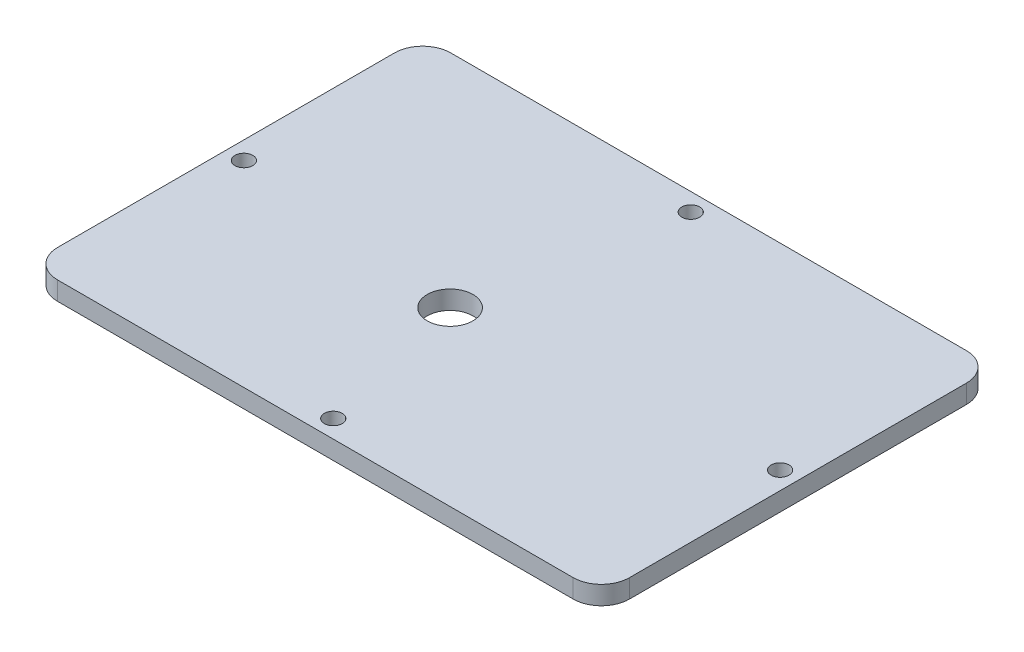
from build123d import *

# Parameters (mm, degrees)
SKETCH1_W           = 101.6
SKETCH1_H           = 69.85
BOSS_EXTRUDE1_DEPTH = 3.302
SKETCH4_R           = 1.5875
CUT_EXTRUDE1_DEPTH  = 4.302
FILLET1_R           = 5
SKETCH5_R           = 4.064
CUT_EXTRUDE2_DEPTH  = 4.302


with BuildPart() as part:
    # Sketch1 → Boss-Extrude1 (new body)
    with BuildSketch(Plane(origin=(0, 0, 0), x_dir=(1, 0, 0), z_dir=(0, 1, 0))):
        Rectangle(SKETCH1_W, SKETCH1_H)
    extrude(amount=BOSS_EXTRUDE1_DEPTH)

    # Sketch4 → Cut-Extrude1 (cut, through all)
    with BuildSketch(Plane(origin=(0, 0, 0), x_dir=(-1, 0, 0), z_dir=(0, -1, 0))):
        with Locations((0, 31.75)):
            Circle(SKETCH4_R)
        with Locations((-47.625, 0)):
            Circle(SKETCH4_R)
        with Locations((0, -31.75)):
            Circle(SKETCH4_R)
        with Locations((47.625, 0)):
            Circle(SKETCH4_R)
    extrude(amount=-CUT_EXTRUDE1_DEPTH, mode=Mode.SUBTRACT)

    # Fillet1
    fillet1_edges = [part.edges().sort_by_distance(p)[0] for p in [
        (50.8, 1.651, 34.925),
        (-50.8, 1.651, 34.925),
        (-50.8, 1.651, -34.925),
        (50.8, 1.651, -34.925),
    ]]
    fillet(fillet1_edges, radius=FILLET1_R)

    # Sketch5 → Cut-Extrude2 (cut, through all)
    with BuildSketch(Plane(origin=(0, 3.302, 0), x_dir=(1, 0, 0), z_dir=(0, 1, 0))):
        with Locations((-6.671406789, -4.328326436)):
            Circle(SKETCH5_R)
    extrude(amount=-CUT_EXTRUDE2_DEPTH, mode=Mode.SUBTRACT)


solid = part.part
